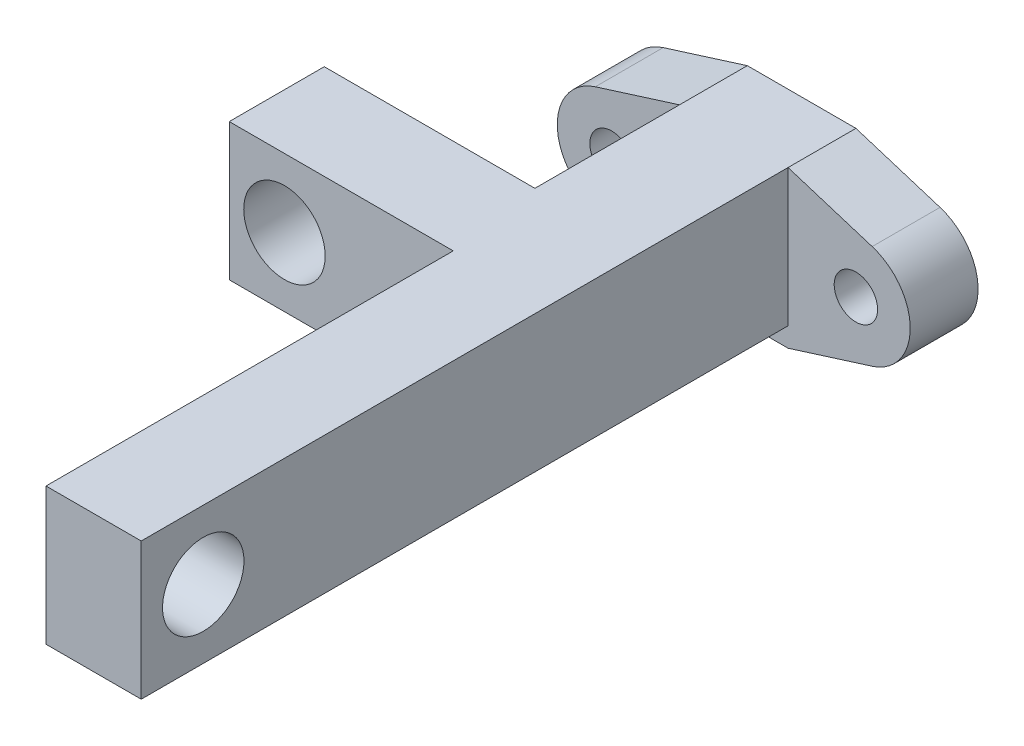
from build123d import *

# Parameters (mm, degrees)
ESBO_O1_R                = 1.598160281
ESBO_O1_R_2              = 1.600993429
RESSALTO_EXTRUS_O1_DEPTH = 5
ESBO_O2_W                = 8.00000038
ESBO_O2_H                = 10.097505558
RESSALTO_EXTRUS_O2_DEPTH = 17.65
ESBO_O3_W                = 7
ESBO_O3_H                = 10.097505558
RESSALTO_EXTRUS_O3_DEPTH = 15.515714
ESBO_O4_R                = 3
CORTE_EXTRUS_O1_DEPTH    = 13
ESBO_O5_W                = 7.0157148
ESBO_O5_H                = 10.097505558
RESSALTO_EXTRUS_O4_DEPTH = 30
ESBO_O6_R                = 3
CORTE_EXTRUS_O2_DEPTH    = 30


with BuildPart() as part:
    # Esboço1 → Ressalto-extrusão1 (new body)
    with BuildSketch(Plane.XY):
        with BuildLine():
            Line((-10.199065979, -3.817665654), (-4.00000019, -5.764999893))
            Line((-4.00000019, -5.764999893), (4.00000019, -5.764999893))
            Line((4.00000019, -5.764999893), (10.197782, -3.817301838))
            ThreePointArc((10.197782, -3.817301838), (12.999977706, 0.001566069), (10.195969576, 3.8191034))
            Line((10.195969576, 3.8191034), (4.00000019, 5.763000809))
            Line((4.00000019, 5.763000809), (-4.00000019, 5.763000809))
            Line((-4.00000019, 5.763000809), (-10.199143851, 3.815503142))
            ThreePointArc((-10.199143851, 3.815503142), (-13.000622723, -0.001109837), (-10.199065979, -3.817665654))
        make_face()
        with Locations((8.997973452, 0.000616233)):
            Circle(ESBO_O1_R, mode=Mode.SUBTRACT)
        with Locations((-9.000145119, -0.001069025)):
            Circle(ESBO_O1_R_2, mode=Mode.SUBTRACT)
    extrude(amount=RESSALTO_EXTRUS_O1_DEPTH)

    # Esboço2 → Ressalto-extrusão2 (add)
    with BuildSketch(Plane.XY.offset(5)):
        with Locations((0, 0.71424803)):
            Rectangle(ESBO_O2_W, ESBO_O2_H)
    extrude(amount=RESSALTO_EXTRUS_O2_DEPTH)

    # Esboço3 → Ressalto-extrusão3 (add)
    with BuildSketch(Plane.ZY.offset(4.00000019)):
        with Locations((19.15, 0.71424803)):
            Rectangle(ESBO_O3_W, ESBO_O3_H)
    extrude(amount=RESSALTO_EXTRUS_O3_DEPTH)

    # Esboço4 → Corte-extrusão1 (cut)
    with BuildSketch(Plane(origin=(0, 0, 15.65), x_dir=(-1, 0, 0), z_dir=(0, 0, -1))):
        with Locations((15.448687317, 0.71424803)):
            Circle(ESBO_O4_R)
    extrude(amount=-CORTE_EXTRUS_O1_DEPTH, mode=Mode.SUBTRACT)

    # Esboço5 → Ressalto-extrusão4 (add)
    with BuildSketch(Plane.XY.offset(22.65)):
        with Locations((0.49214279, 0.71424803)):
            Rectangle(ESBO_O5_W, ESBO_O5_H)
    extrude(amount=RESSALTO_EXTRUS_O4_DEPTH)

    # Esboço6 → Corte-extrusão2 (cut)
    with BuildSketch(Plane(origin=(4.00000019, 0, 0), x_dir=(0, 0, -1), z_dir=(1, 0, 0))):
        with Locations((-48.08055434, 0.71424803)):
            Circle(ESBO_O6_R)
    extrude(amount=-CORTE_EXTRUS_O2_DEPTH, mode=Mode.SUBTRACT)


solid = part.part
